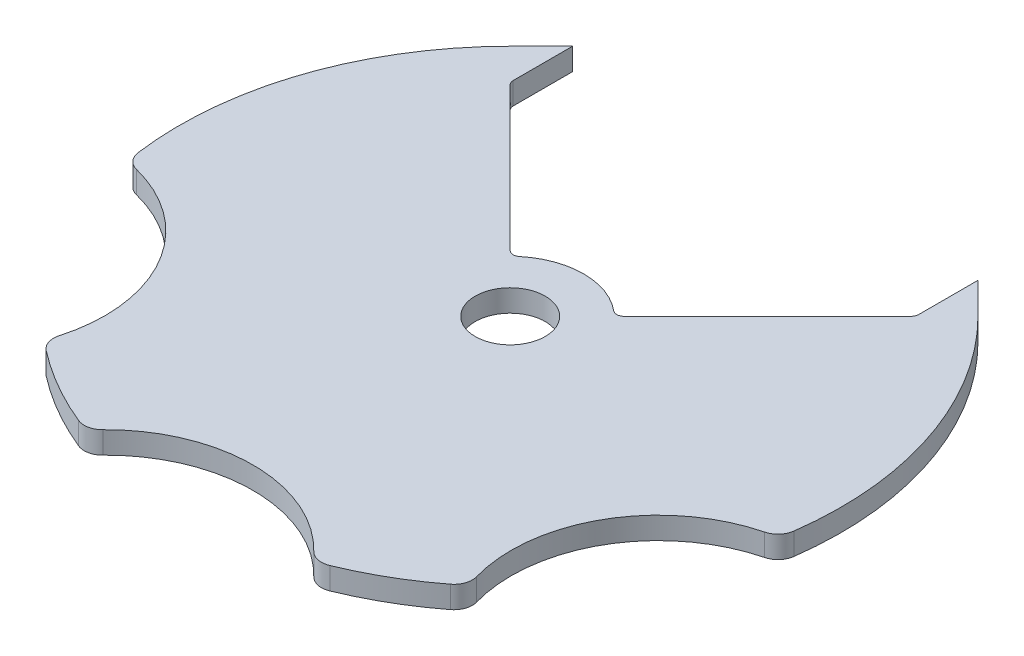
from build123d import *

# Parameters (mm, degrees)
SKETCH1_R           = 4.7625
BOSS_EXTRUDE1_DEPTH = 3
BOSS_EXTRUDE2_DEPTH = 3
FILLET1_R           = 1
SKETCH4_R           = 20
CUT_EXTRUDE1_DEPTH  = 10
FILLET2_R           = 2.5


with BuildPart() as part:
    # Sketch1 → Boss-Extrude1 (new body)
    with BuildSketch(Plane(origin=(0, 0, 0), x_dir=(1, 0, 0), z_dir=(0, 1, 0))):
        with BuildLine():
            Line((-31.819805153, 31.819805153), (-7.071067812, 7.071067812))
            ThreePointArc((-7.071067812, 7.071067812), (0, 10), (7.071067812, 7.071067812))
            Line((7.071067812, 7.071067812), (31.819805153, 31.819805153))
            ThreePointArc((31.819805153, 31.819805153), (0, -45), (-31.819805153, 31.819805153))
        make_face()
        Circle(SKETCH1_R, mode=Mode.SUBTRACT)
    extrude(amount=BOSS_EXTRUDE1_DEPTH)

    # Sketch3 → Boss-Extrude2 (add)
    with BuildSketch(Plane(origin=(0, 3, 0), x_dir=(1, 0, 0), z_dir=(0, 1, 0))):
        Polygon((-31.819805153, 31.819805153), (-27.577164466, 36.062445841), (-27.577164466, 27.577164466), align=None)
        Polygon((27.577164466, 27.577164466), (31.819805153, 31.819805153), (27.577164466, 36.062445841), align=None)
    extrude(amount=-BOSS_EXTRUDE2_DEPTH)

    # Fillet1
    fillet1_edges = [part.edges().sort_by_distance(p)[0] for p in [
        (-27.577164466, 1.5, -27.577164466),
        (27.577164466, 1.5, -27.577164466),
        (7.071067812, 1.5, -7.071067812),
        (-7.071067812, 1.5, -7.071067812),
    ]]
    fillet(fillet1_edges, radius=FILLET1_R)

    # Sketch4 → Cut-Extrude1 (cut)
    with BuildSketch(Plane(origin=(0, 3, 0), x_dir=(1, 0, 0), z_dir=(0, 1, 0))):
        with Locations((-47.631397208, -27.5)):
            Circle(SKETCH4_R)
        with Locations((47.631397208, -27.5)):
            Circle(SKETCH4_R)
        with Locations((0, -55)):
            Circle(SKETCH4_R)
    extrude(amount=-CUT_EXTRUDE1_DEPTH, mode=Mode.SUBTRACT)

    # Fillet2
    fillet2_edges = [part.edges().sort_by_distance(p)[0] for p in [
        (15.427784317, 1.5, 42.272727273),
        (-15.427784317, 1.5, 42.272727273),
        (44.323147864, 1.5, 7.775510494),
        (28.895363547, 1.5, 34.497216779),
        (-28.895363547, 1.5, 34.497216779),
        (-44.323147864, 1.5, 7.775510494),
    ]]
    fillet(fillet2_edges, radius=FILLET2_R)


solid = part.part
